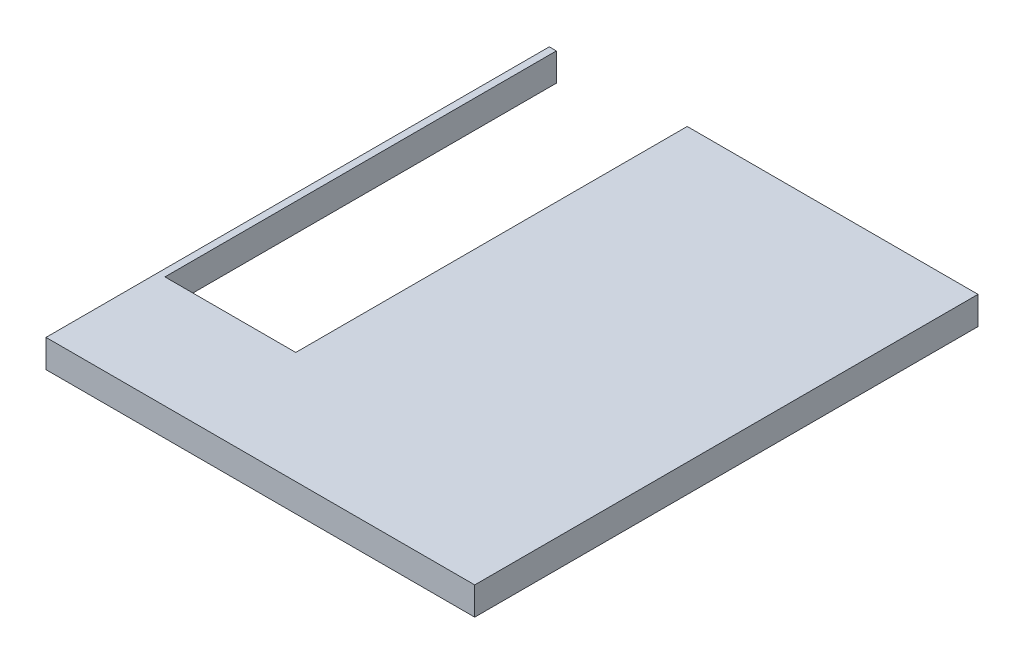
from build123d import *

# Parameters (mm, degrees)
ESBO_O1_W                = 2300
ESBO_O1_H                = 150
RESSALTO_EXTRUS_O1_DEPTH = 2700
ESBO_O3_W                = 702
ESBO_O3_H                = 2100
PORTA_DEPTH              = 151


with BuildPart() as part:
    # Esboço1 → Ressalto-extrusão1 (new body)
    with BuildSketch(Plane.XY):
        with Locations((1150, 75)):
            Rectangle(ESBO_O1_W, ESBO_O1_H)
    extrude(amount=RESSALTO_EXTRUS_O1_DEPTH)

    # Esboço3 → PORTA (cut, through all)
    with BuildSketch(Plane(origin=(0, 150, 0), x_dir=(1, 0, 0), z_dir=(0, 1, 0))):
        with Locations((389, -1050)):
            Rectangle(ESBO_O3_W, ESBO_O3_H)
    extrude(amount=-PORTA_DEPTH, mode=Mode.SUBTRACT)


solid = part.part
